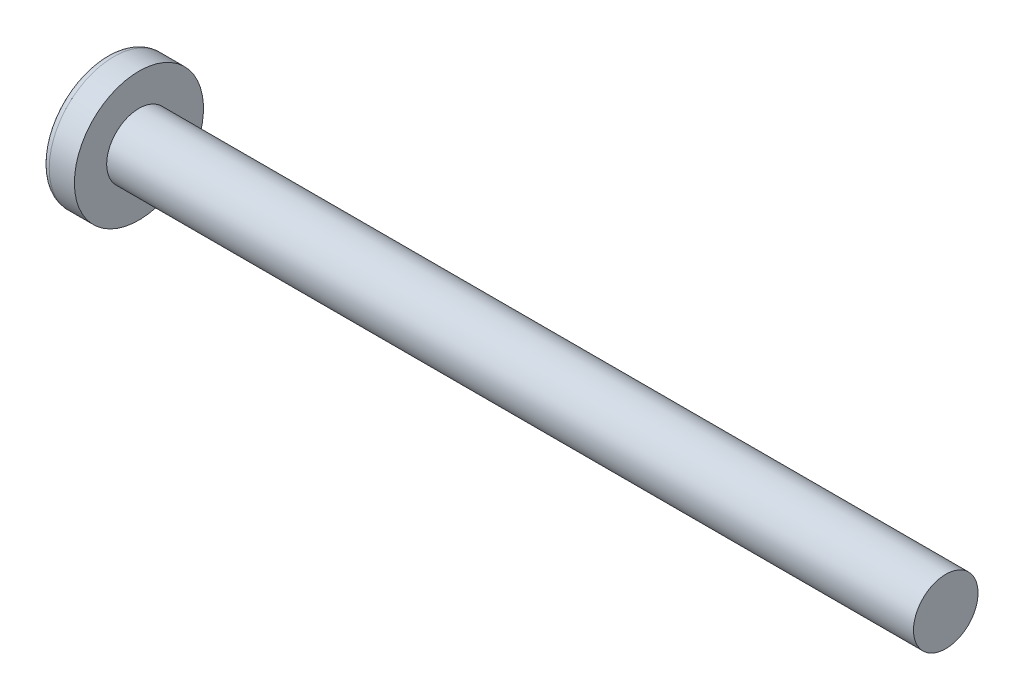
from build123d import *

# Parameters (mm, degrees)
SKETCH3_W         = 0.48
SKETCH3_H         = 1.82
SKETCH4_W         = 0.24
SKETCH4_H         = 0.24
CIRPATTERN1_COUNT = 2
CIRPATTERN1_ANGLE = 90


with BuildPart() as part:
    # BodySke → Base-Revolve (revolve)
    with BuildSketch(Plane.XY):
        with BuildLine():
            Line((1.6, 1), (1.6, 2))
            Line((1.6, 2), (0.820084035, 2))
            ThreePointArc((0.820084035, 2), (0.712029995, 1.974299613), (0.627117876, 1.902702703))
            ThreePointArc((0.627117876, 1.902702703), (0.160820604, 1.001692868), (0, 0))
            Line((0, 0), (26.6, 0))
            Line((26.6, 0), (26.6, 1))
            Line((26.6, 1), (1.6, 1))
        make_face()
    revolve(axis=Axis((-25.4, 0, 0), (1, 0, 0)))

    # Sketch3 → Cut-Loft1 section 0
    with BuildSketch(Plane(origin=(0, 0, 0), x_dir=(0, 0, -1), z_dir=(1, 0, 0))):
        Rectangle(SKETCH3_W, SKETCH3_H)
    # Sketch4 → Cut-Loft1 section 1
    with BuildSketch(Plane(origin=(1.19, 0, 0), x_dir=(0, 0, -1), z_dir=(1, 0, 0))):
        Rectangle(SKETCH4_W, SKETCH4_H)
    cut_loft1 = loft(mode=Mode.SUBTRACT)

    # CirPattern1: Cut-Loft1 ×2 about axis
    cirpattern1_axis = Axis((0, 0, 0), (1, 0, 0))
    for i in range(1, CIRPATTERN1_COUNT):
        add(cut_loft1.rotate(cirpattern1_axis, i * CIRPATTERN1_ANGLE / (CIRPATTERN1_COUNT - 1)), mode=Mode.SUBTRACT)


solid = part.part
